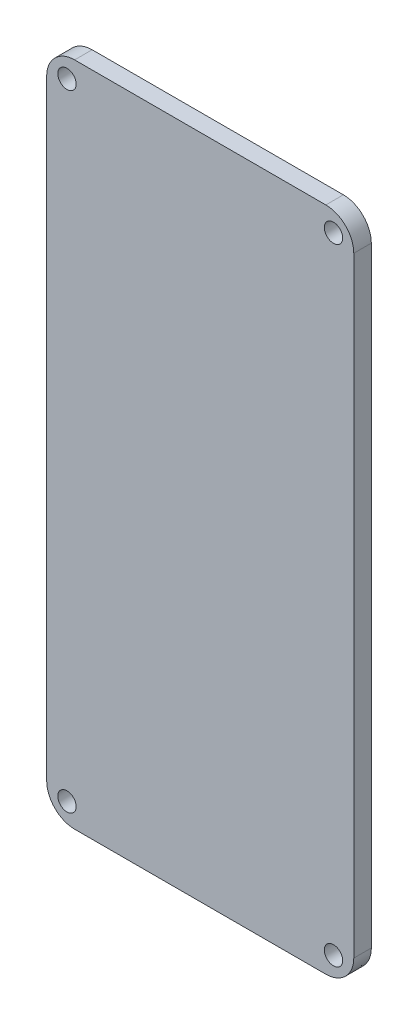
from build123d import *

# Parameters (mm, degrees)
MODEL_RX                = 1.571217391
MODEL_RY                = 1.571217391
SALIENTE_EXTRUIR1_DEPTH = 3


with BuildPart() as part:
    # Model → Saliente-Extruir1 (new body)
    with BuildSketch(Plane.XY):
        with BuildLine():
            Line((-30.420546945, 55.798863477), (12.566275653, 55.798863477))
            add(Edge.make_bspline(
                [(12.566275653, 55.798863477), (15.193133044, 55.798863477), (17.34238, 53.649616521), (17.34238, 51.02266)],
                knots=[0.111111111, 0.111111111, 0.111111111, 0.111111111, 0.222222222, 0.222222222, 0.222222222, 0.222222222], degree=3))
            Line((17.34238, 51.02266), (17.34238, -53.425032149))
            add(Edge.make_bspline(
                [(17.34238, -53.425032149), (17.34238, -56.05198867), (15.193133044, -58.201235626), (12.566275653, -58.201235626)],
                knots=[0.333333333, 0.333333333, 0.333333333, 0.333333333, 0.444444444, 0.444444444, 0.444444444, 0.444444444], degree=3))
            Line((12.566275653, -58.201235626), (-30.420546945, -58.201235626))
            add(Edge.make_bspline(
                [(-30.420546945, -58.201235626), (-33.047404336, -58.201235626), (-35.196750422, -56.05198867), (-35.196750422, -53.425032149)],
                knots=[0.555555556, 0.555555556, 0.555555556, 0.555555556, 0.666666667, 0.666666667, 0.666666667, 0.666666667], degree=3))
            Line((-35.196750422, -53.425032149), (-35.196750422, 51.02266))
            add(Edge.make_bspline(
                [(-35.196750422, 51.02266), (-35.196750422, 53.649616521), (-33.047404336, 55.798863477), (-30.420546945, 55.798863477)],
                knots=[0.777777778, 0.777777778, 0.777777778, 0.777777778, 1, 1, 1, 1], degree=3))
        make_face()
        with Locations(Location((-31.727185206, 52.3291), (0, 0, 90))):
            Ellipse(MODEL_RX, MODEL_RY, mode=Mode.SUBTRACT)
        with Locations(Location((13.872814783, 52.3291), (0, 0, 90))):
            Ellipse(MODEL_RX, MODEL_RY, mode=Mode.SUBTRACT)
        with Locations(Location((-31.727185206, -54.73176954), (0, 0, 180))):
            Ellipse(MODEL_RX, MODEL_RY, mode=Mode.SUBTRACT)
        with Locations(Location((13.872814783, -54.73176954), (0, 0, 90))):
            Ellipse(MODEL_RX, MODEL_RY, mode=Mode.SUBTRACT)
    extrude(amount=SALIENTE_EXTRUIR1_DEPTH)


solid = part.part
